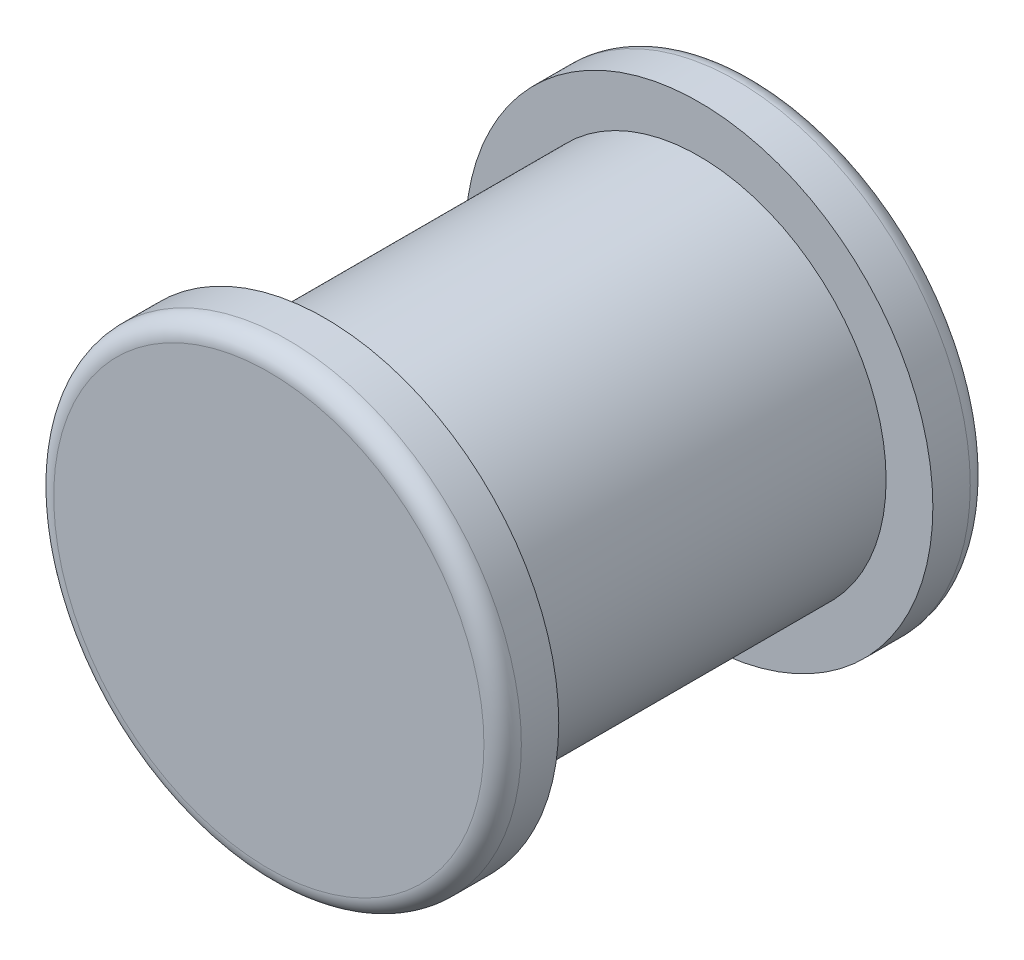
from build123d import *

# Parameters (mm, degrees)
SKETCH1_R            = 10
BOSS_EXTRUDE1_DEPTH  = 20
SKETCH2_R            = 12.5
BOSS_EXTRUDE2_DEPTH  = 3
FILLET1_R            = 1
FILLET1_OF_MIRROR1_R = 1


with BuildPart() as part:
    # Sketch1 → Boss-Extrude1 (new body)
    with BuildSketch(Plane.XY):
        Circle(SKETCH1_R)
    extrude(amount=BOSS_EXTRUDE1_DEPTH)

    # Sketch2 → Boss-Extrude2 (add)
    with BuildSketch(Plane(origin=(0, 0, 0), x_dir=(-1, 0, 0), z_dir=(0, 0, -1))):
        Circle(SKETCH2_R)
    boss_extrude2 = extrude(amount=BOSS_EXTRUDE2_DEPTH)

    # Fillet1
    fillet1_edges = [part.edges().sort_by_distance(p)[0] for p in [
        (12.5, 0, -3),
    ]]
    fillet(fillet1_edges, radius=FILLET1_R)

    # Mirror1: Boss-Extrude2 across plane
    add(boss_extrude2.mirror(Plane.XY.offset(10)))

    # Fillet1 of Mirror1
    fillet1_of_mirror1_edges = [part.edges().sort_by_distance(p)[0] for p in [
        (12.5, 0, 23),
    ]]
    fillet(fillet1_of_mirror1_edges, radius=FILLET1_OF_MIRROR1_R)


solid = part.part
